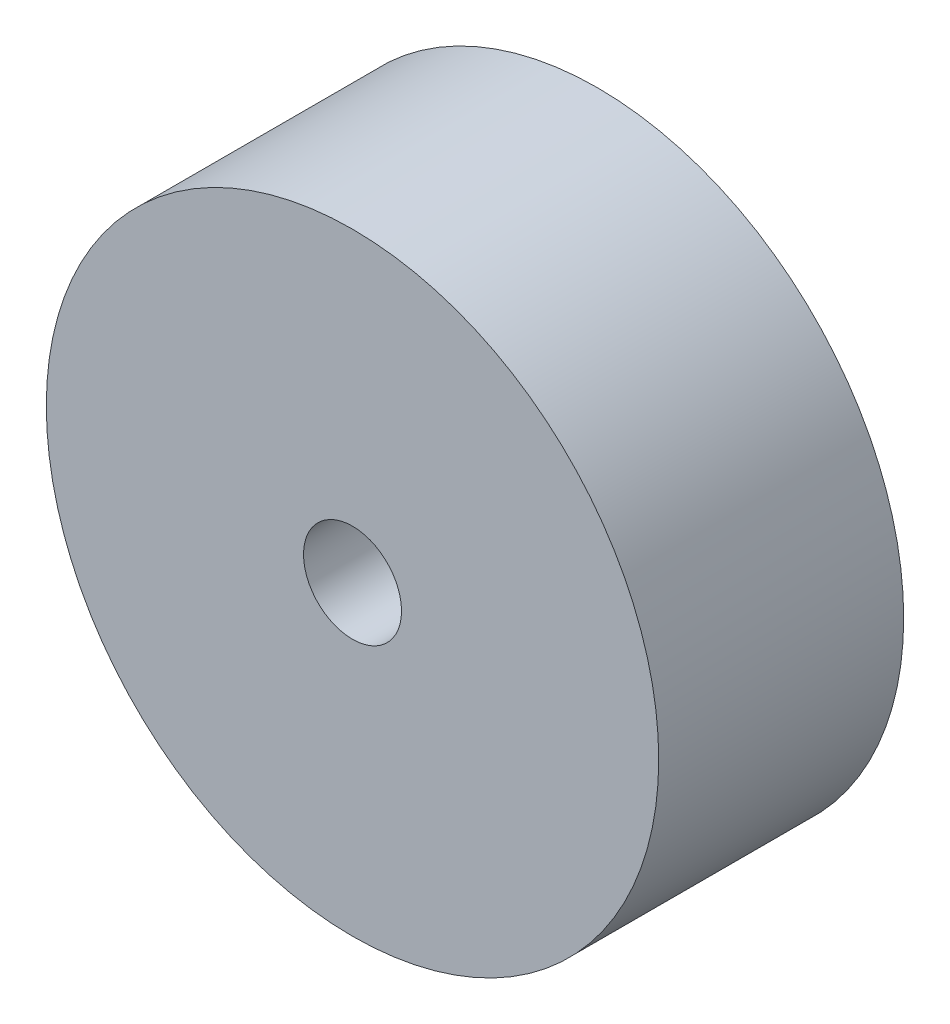
from build123d import *

# Parameters (mm, degrees)
CROQUIS1_R              = 0.625
CROQUIS1_R_2            = 0.1
SALIENTE_EXTRUIR1_DEPTH = 0.5
REDONDEO1_R             = 0.15


with BuildPart() as part:
    # Croquis1 → Saliente-Extruir1 (new body)
    with BuildSketch(Plane.XY):
        Circle(CROQUIS1_R)
        Circle(CROQUIS1_R_2, mode=Mode.SUBTRACT)
    extrude(amount=SALIENTE_EXTRUIR1_DEPTH)

    # Croquis2 → Cortar-Revolución3 (revolve, cut)
    with BuildSketch(Plane(origin=(0, 0, 0), x_dir=(1, 0, 0), z_dir=(0, 1, 0))):
        with BuildLine():
            Line((0, 0), (0, -0.125))
            ThreePointArc((0, -0.125), (0.153093109, -0.092326598), (0.279508497, 0))
            Line((0.279508497, 0), (0, 0))
        make_face()
    revolve(axis=Axis((0, 0, 0), (0, 0, 1)), mode=Mode.SUBTRACT)

    # Redondeo1
    redondeo1_edges = [part.edges().sort_by_distance(p)[0] for p in [
        (-0.1, 0, 0.111420807),
    ]]
    fillet(redondeo1_edges, radius=REDONDEO1_R)


solid = part.part
